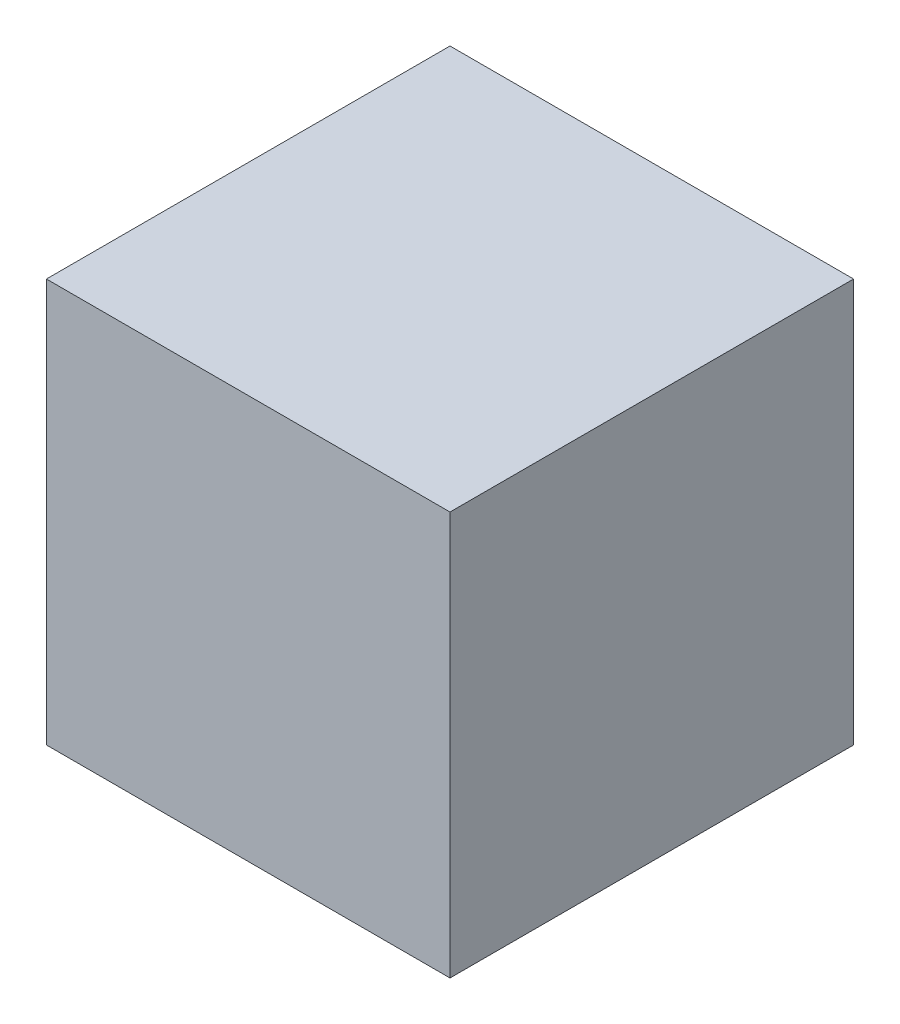
from build123d import *

# Parameters (mm, degrees)
SKIZZE1_W                       = 50
SKIZZE1_H                       = 50
AUFSATZ_LINEAR_AUSTRAGEN1_DEPTH = 50


with BuildPart() as part:
    # Skizze1 → Aufsatz-Linear austragen1 (new body)
    with BuildSketch(Plane.XY):
        with Locations((25, 25)):
            Rectangle(SKIZZE1_W, SKIZZE1_H)
    extrude(amount=AUFSATZ_LINEAR_AUSTRAGEN1_DEPTH)


solid = part.part
